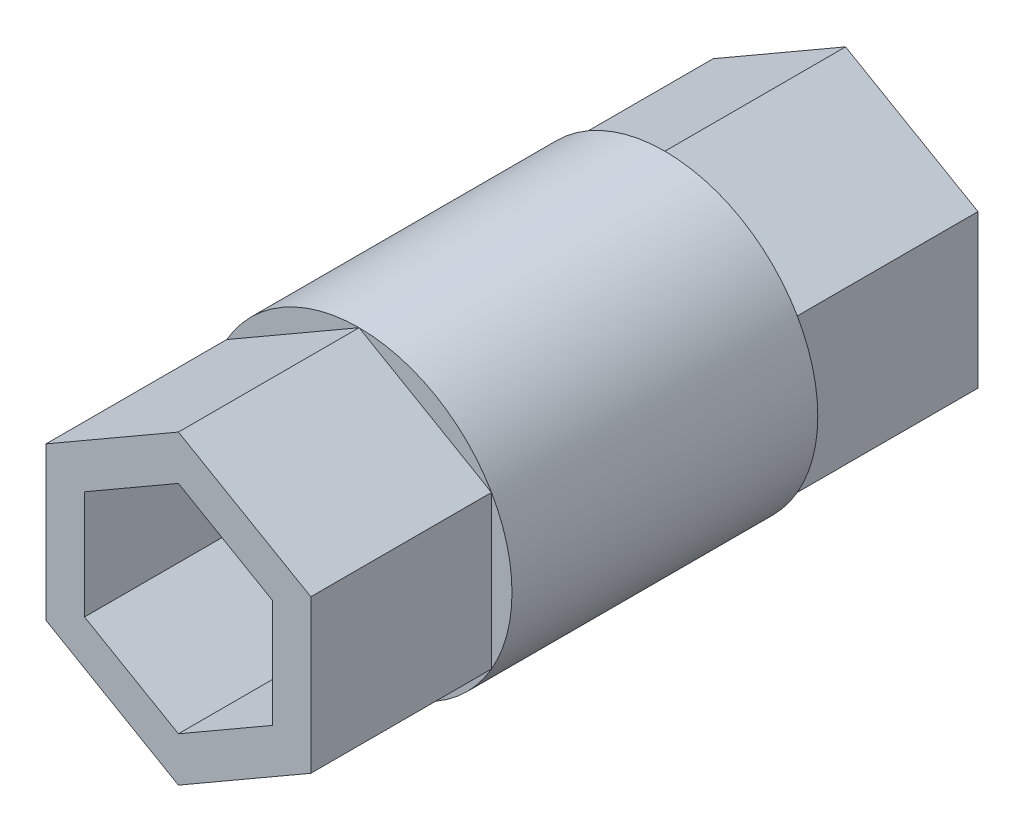
from build123d import *

# Parameters (mm, degrees)
SKETCH1_R           = 11
SKETCH1_R_2         = 6.4
BOSS_EXTRUDE1_DEPTH = 11
BOSS_EXTRUDE2_DEPTH = 24
CUT_EXTRUDE3_DEPTH  = 51.457903246


with BuildPart() as part:
    # Sketch1 → Boss-Extrude1 (new, symmetric)
    with BuildSketch(Plane.XY):
        Circle(SKETCH1_R)
        Circle(SKETCH1_R_2, mode=Mode.SUBTRACT)
    extrude(amount=BOSS_EXTRUDE1_DEPTH, both=True)

    # Sketch1_3 → Boss-Extrude2 (add, symmetric)
    with BuildSketch(Plane.XY):
        Polygon((-9.526279442, -5.5), (0, -11), (9.526279442, -5.5), (9.526279442, 5.5), (0, 11), (-9.526279442, 5.5), align=None)
    extrude(amount=BOSS_EXTRUDE2_DEPTH, both=True)

    # Sketch2 → Cut-Extrude3 (cut, through all)
    with BuildSketch(Plane.XY.offset(24)):
        Polygon((0, -7.8), (6.75499815, -3.9), (6.75499815, 3.9), (0, 7.8), (-6.75499815, 3.9), (-6.75499815, -3.9), align=None)
    extrude(amount=-CUT_EXTRUDE3_DEPTH, mode=Mode.SUBTRACT)


solid = part.part
